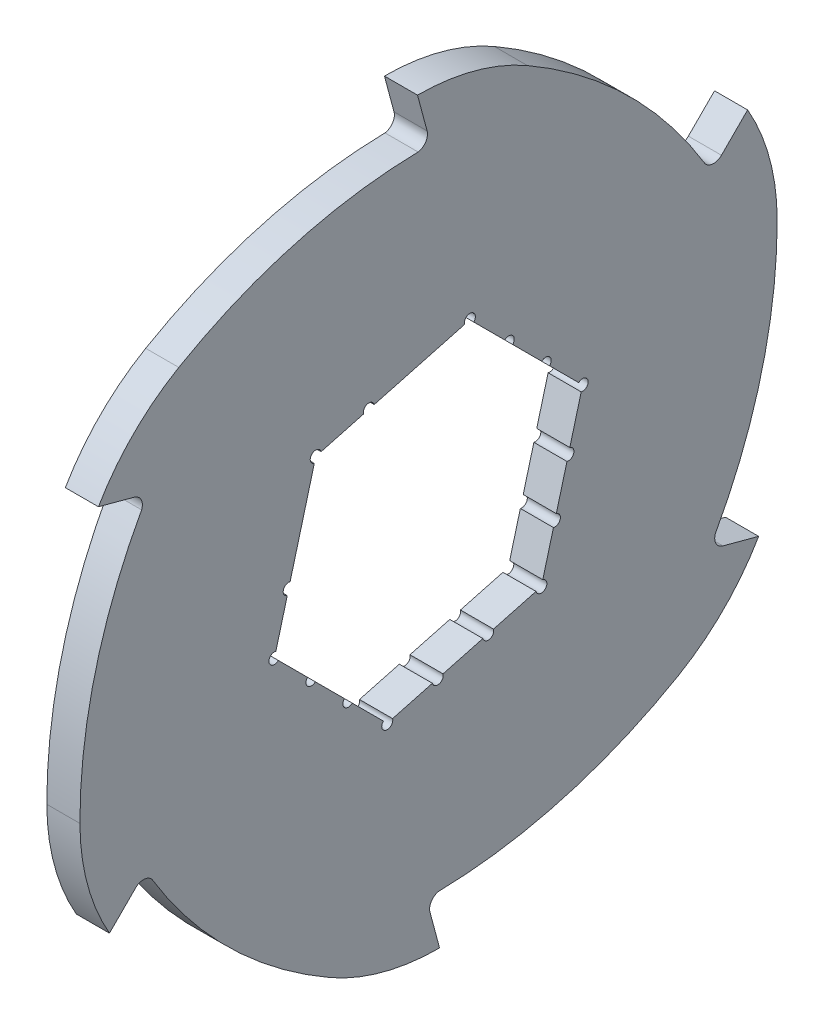
from build123d import *

# Parameters (mm, degrees)
SKETCH1_R                = 59
EXTRUDE1_DEPTH           = 3
EXTRUDE2_DEPTH           = 3
CIRPATTERN1_COUNT        = 6
F_2_0_2_DIAMETER_HOLE1_D = 2
F_2_0_2_DIAMETER_HOLE3_D = 2
F_2_0_2_DIAMETER_HOLE4_D = 2
CIRPATTERN2_COUNT        = 6
CIRPATTERN3_COUNT        = 4
CIRPATTERN3_ANGLE        = 180


with BuildPart() as part:
    # Sketch1 → Extrude1 (new, symmetric)
    with BuildSketch(Plane(origin=(0, 0, 0), x_dir=(0, 0, -1), z_dir=(1, 0, 0))):
        Circle(SKETCH1_R)
        Polygon((27.939644545, 7.486405193), (7.486405193, 27.939644545), (-20.453239352, 20.453239352), (-27.939644545, -7.486405193), (-7.486405193, -27.939644545), (20.453239352, -20.453239352), align=None, mode=Mode.SUBTRACT)
    extrude(amount=EXTRUDE1_DEPTH, both=True)

    # Sketch2 → Extrude2 (add, symmetric)
    with BuildSketch(Plane(origin=(0, 0, 0), x_dir=(0, 0, -1), z_dir=(1, 0, 0))):
        with BuildLine():
            Line((-2, 67.961805723), (-0.262709442, 61.478149092))
            ThreePointArc((-0.262709442, 61.478149092), (-0.58620663, 59.77173183), (-2.122608272, 58.961805723))
            ThreePointArc((-2.122608272, 58.961805723), (28.679663449, 51.560419941), (51.21368579, 29.294340542))
            ThreePointArc((51.21368579, 29.294340542), (36.791707484, 48.186627241), (17.927108603, 62.644803614))
            ThreePointArc((17.927108603, 62.644803614), (8.312130826, 66.609702921), (-2, 67.961805723))
        make_face()
    extrude2 = extrude(amount=EXTRUDE2_DEPTH, both=True)

    # CirPattern1: Extrude2 ×6 about axis
    cirpattern1_axis = Axis((0, 0, 0), (1, 0, 0))
    for i in range(1, CIRPATTERN1_COUNT):
        add(extrude2.rotate(cirpattern1_axis, i * 360 / CIRPATTERN1_COUNT))

    # Ø2.0 (2) Diameter Hole1 (through all)
    with Locations(Plane(origin=(3, 0, 0), x_dir=(0, 0, -1), z_dir=(1, 0, 0))):
        with Locations((7.486405193, 27.939644545), (27.939644545, 7.486405193), (20.453239352, -20.453239352), (-7.486405193, -27.939644545), (-27.939644545, -7.486405193), (-20.453239352, 20.453239352)):
            Hole(F_2_0_2_DIAMETER_HOLE1_D / 2)

    # Ø2.0 (2) Diameter Hole3 (through all)
    with Locations(Plane(origin=(3, 0, 0), x_dir=(0, 0, -1), z_dir=(1, 0, 0))):
        with Locations((14.539853904, 20.886195834)):
            f_2_0_2_diameter_hole3 = Hole(F_2_0_2_DIAMETER_HOLE3_D / 2)

    # Ø2.0 (2) Diameter Hole4 (through all)
    with Locations(Plane(origin=(3, 0, 0), x_dir=(0, 0, -1), z_dir=(1, 0, 0))):
        with Locations((21.239749224, 14.186300513)):
            f_2_0_2_diameter_hole4 = Hole(F_2_0_2_DIAMETER_HOLE4_D / 2)

    # CirPattern2: Ø2.0 (2) Diameter Hole3 ×6 about axis
    cirpattern2_axis = Axis((0, 0, 0), (1, 0, 0))
    for i in range(1, CIRPATTERN2_COUNT):
        add(f_2_0_2_diameter_hole3.rotate(cirpattern2_axis, i * 360 / CIRPATTERN2_COUNT), mode=Mode.SUBTRACT)

    # CirPattern3: Ø2.0 (2) Diameter Hole4 ×4 about axis
    cirpattern3_axis = Axis((0, 0, 0), (-1, 0, 0))
    for i in range(1, CIRPATTERN3_COUNT):
        add(f_2_0_2_diameter_hole4.rotate(cirpattern3_axis, i * CIRPATTERN3_ANGLE / (CIRPATTERN3_COUNT - 1)), mode=Mode.SUBTRACT)


solid = part.part
